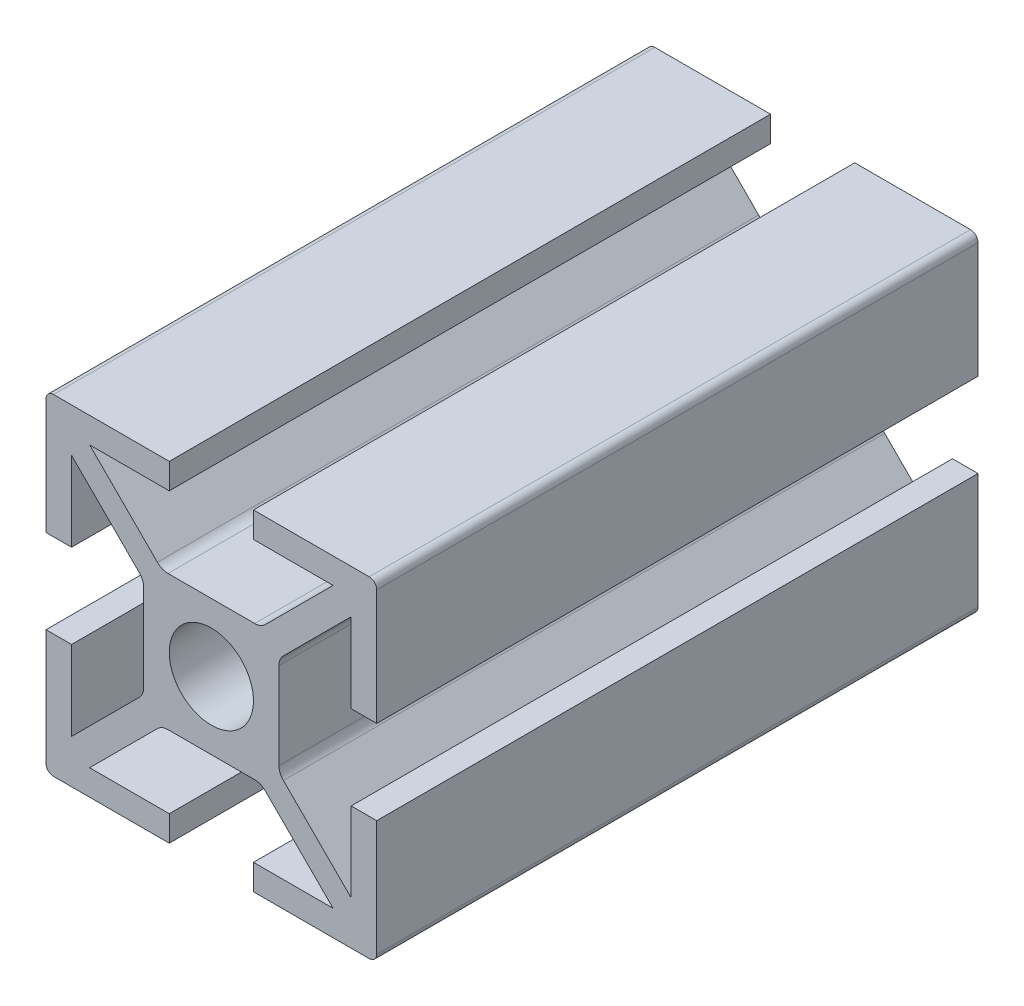
from build123d import *

# Parameters (mm, degrees)
EXTRUSION1_DEPTH        = 40
ESQUISSE2_R             = 2.8
ENL_V_MAT_EXTRU_1_DEPTH = 41
CONG_1_R                = 0.5
CONG_2_R                = 1


with BuildPart() as part:
    # Esquisse1 → Extrusion1 (new body)
    with BuildSketch(Plane.XY):
        Polygon((-2.8, 11), (-2.8, 9.3), (-8.097918472, 9.3), (-3.297918472, 4.5), (3.297918472, 4.5), (8.097918472, 9.3), (2.8, 9.3), (2.8, 11), (11, 11), (11, 2.8), (9.3, 2.8), (9.3, 8.097918472), (4.5, 3.297918472), (4.5, -3.297918472), (9.3, -8.097918472), (9.3, -2.8), (11, -2.8), (11, -11), (2.8, -11), (2.8, -9.3), (8.097918472, -9.3), (3.297918472, -4.5), (-3.297918472, -4.5), (-8.097918472, -9.3), (-2.8, -9.3), (-2.8, -11), (-11, -11), (-11, -2.8), (-9.3, -2.8), (-9.3, -8.097918472), (-4.5, -3.297918472), (-4.5, 3.297918472), (-9.3, 8.097918472), (-9.3, 2.8), (-11, 2.8), (-11, 11), align=None)
    extrude(amount=EXTRUSION1_DEPTH)

    # Esquisse2 → Enlèv. mat.-Extru.1 (cut, through all)
    with BuildSketch(Plane(origin=(0, 0, 0), x_dir=(-1, 0, 0), z_dir=(0, 0, -1))):
        Circle(ESQUISSE2_R)
    extrude(amount=-ENL_V_MAT_EXTRU_1_DEPTH, mode=Mode.SUBTRACT)

    # Congé1
    cong_1_edges = [part.edges().sort_by_distance(p)[0] for p in [
        (-11, 11, 20),
        (11, 11, 20),
        (11, -11, 20),
        (-11, -11, 20),
    ]]
    fillet(cong_1_edges, radius=CONG_1_R)

    # Congé2
    cong_2_edges = [part.edges().sort_by_distance(p)[0] for p in [
        (-4.5, -3.297918472, 20),
        (-4.5, 3.297918472, 20),
        (-3.297918472, 4.5, 20),
        (3.297918472, 4.5, 20),
        (4.5, 3.297918472, 20),
        (4.5, -3.297918472, 20),
        (3.297918472, -4.5, 20),
        (-3.297918472, -4.5, 20),
    ]]
    fillet(cong_2_edges, radius=CONG_2_R)


solid = part.part
